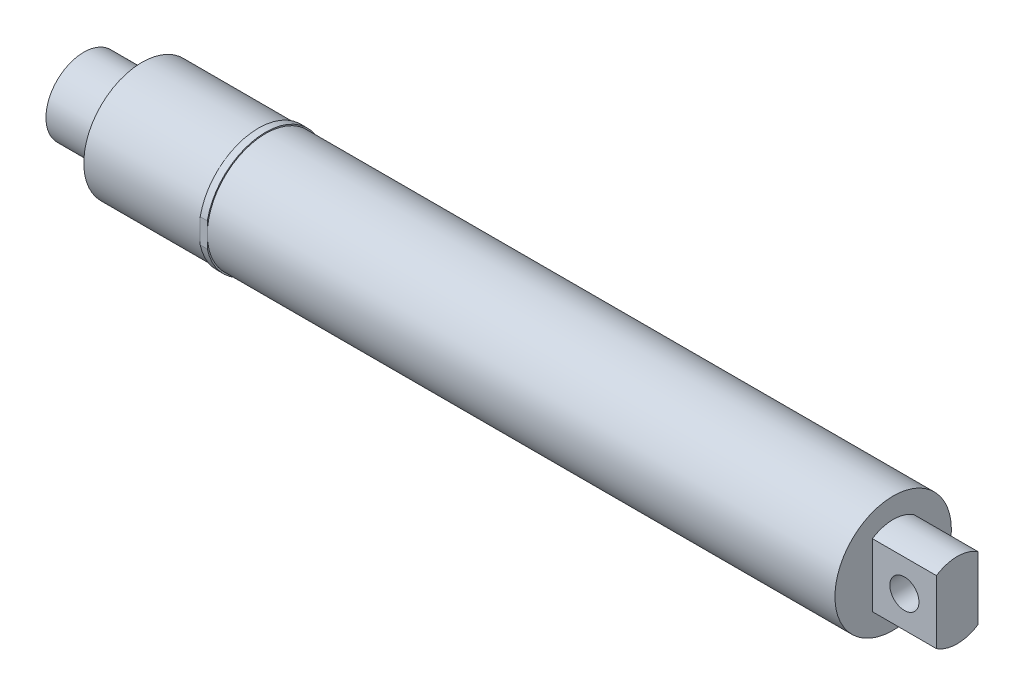
from build123d import *

# Parameters (mm, degrees)
CROQUIS2_R                   = 12.7
SALIENTE_EXTRUIR1_DEPTH      = 190.5
CROQUIS3_R                   = 12.7
CROQUIS3_R_2                 = 8.255
CORTAR_EXTRUIR1_DEPTH        = 12.7
CROQUIS4_R                   = 2.54
CORTAR_EXTRUIR2_DEPTH        = 170.18
CROQUIS6_R                   = 12.7
CROQUIS6_R_2                 = 8.255
CORTAR_EXTRUIR6_DEPTH        = 16.51
CORTAR_EXTRUIR8_DEPTH        = 16.51
CROQUIS9_R                   = 3.175
CORTAR_EXTRUIR9_DEPTH        = 16.51
CROQUIS10_W                  = 1.546124295
CROQUIS10_H                  = 25.4
SALIENTE_EXTRUIR2_DEPTH      = 12.7
SALIENTE_EXTRUIR2_DEPTH_BACK = 12.7
CORTAR_EXTRUIR10_DEPTH       = 64.262
CORTAR_EXTRUIR11_DEPTH       = 64.262
CORTAR_EXTRUIR12_DEPTH       = 64.262


with BuildPart() as part:
    # Croquis2 → Saliente-Extruir1 (new body)
    with BuildSketch(Plane(origin=(0, 0, 0), x_dir=(0, 0, -1), z_dir=(1, 0, 0))):
        Circle(CROQUIS2_R)
    extrude(amount=SALIENTE_EXTRUIR1_DEPTH)

    # Croquis3 → Cortar-Extruir1 (cut)
    with BuildSketch(Plane(origin=(0, 0, 0), x_dir=(0, 0, -1), z_dir=(1, 0, 0))):
        Circle(CROQUIS3_R)
        Circle(CROQUIS3_R_2, mode=Mode.SUBTRACT)
    extrude(amount=CORTAR_EXTRUIR1_DEPTH, mode=Mode.SUBTRACT)

    # Croquis4 → Cortar-Extruir2 (cut)
    with BuildSketch(Plane.ZY):
        Circle(CROQUIS4_R)
    extrude(amount=-CORTAR_EXTRUIR2_DEPTH, mode=Mode.SUBTRACT)

    # Croquis6 → Cortar-Extruir6 (cut)
    with BuildSketch(Plane(origin=(193.04, 0, 0), x_dir=(0, 0, -1), z_dir=(1, 0, 0))):
        Circle(CROQUIS6_R)
        Circle(CROQUIS6_R_2, mode=Mode.SUBTRACT)
    extrude(amount=-CORTAR_EXTRUIR6_DEPTH, mode=Mode.SUBTRACT)

    # Croquis8 → Cortar-Extruir8 (cut)
    with BuildSketch(Plane(origin=(193.04, 0, 0), x_dir=(0, 0, -1), z_dir=(1, 0, 0))):
        with BuildLine():
            Line((-4.533022208, 6.899038677), (-4.533022208, -6.899038677))
            ThreePointArc((-4.533022208, -6.899038677), (-8.255, 0), (-4.533022208, 6.899038677))
        make_face()
        with BuildLine():
            Line((4.533022208, 6.899038677), (4.533022208, -6.899038677))
            ThreePointArc((4.533022208, -6.899038677), (8.255, 0), (4.533022208, 6.899038677))
        make_face()
    extrude(amount=-CORTAR_EXTRUIR8_DEPTH, mode=Mode.SUBTRACT)

    # Croquis9 → Cortar-Extruir9 (cut)
    with BuildSketch(Plane(origin=(0, 0, -4.533022208), x_dir=(-1, 0, 0), z_dir=(0, 0, -1))):
        with Locations((-183.515, 0)):
            Circle(CROQUIS9_R)
    extrude(amount=-CORTAR_EXTRUIR9_DEPTH, mode=Mode.SUBTRACT)

    # Croquis10 → Saliente-Extruir2 (add, two sides)
    with BuildSketch(Plane.XY) as saliente_extruir2_sk:
        with Locations((38.873062148, 0.259017105)):
            Rectangle(CROQUIS10_W, CROQUIS10_H)
    extrude(amount=SALIENTE_EXTRUIR2_DEPTH)
    extrude(saliente_extruir2_sk.sketch, amount=-SALIENTE_EXTRUIR2_DEPTH_BACK)

    # Croquis12 → Cortar-Extruir10 (cut)
    with BuildSketch(Plane(origin=(0, 0, 0), x_dir=(0, 0, -1), z_dir=(1, 0, 0))):
        with BuildLine():
            Line((0, 12.959017105), (-12.7, 12.959017105))
            Line((-12.7, 12.959017105), (-12.7, 2.578007822))
            ThreePointArc((-12.7, 2.578007822), (-8.201453434, 10.033557988), (0, 12.959017105))
        make_face()
    extrude(amount=CORTAR_EXTRUIR10_DEPTH, mode=Mode.SUBTRACT)

    # Croquis13 → Cortar-Extruir11 (cut)
    with BuildSketch(Plane.ZY.offset(-38.1)):
        with BuildLine():
            Line((-12.7, 2.578007822), (-12.7, 12.959017105))
            Line((-12.7, 12.959017105), (0, 12.959017105))
            ThreePointArc((0, 12.959017105), (-8.201453434, 10.033557988), (-12.7, 2.578007822))
        make_face()
    extrude(amount=-CORTAR_EXTRUIR11_DEPTH, mode=Mode.SUBTRACT)

    # Croquis14 → Cortar-Extruir12 (cut)
    with BuildSketch(Plane.ZY.offset(-38.1)):
        with BuildLine():
            Line((12.7, -2.768457402), (12.7, -12.440982895))
            Line((12.7, -12.440982895), (3.765142892, -12.440982895))
            ThreePointArc((3.765142892, -12.440982895), (9.548019164, -8.819846168), (12.7, -2.768457402))
        make_face()
        with BuildLine():
            Line((-12.769462216, -2.428001465), (-12.7, -12.440982895))
            Line((-12.7, -12.440982895), (-3.765142892, -12.440982895))
            ThreePointArc((-3.765142892, -12.440982895), (-9.66505255, -8.691439213), (-12.769462216, -2.428001465))
        make_face()
    extrude(amount=-CORTAR_EXTRUIR12_DEPTH, mode=Mode.SUBTRACT)


solid = part.part
